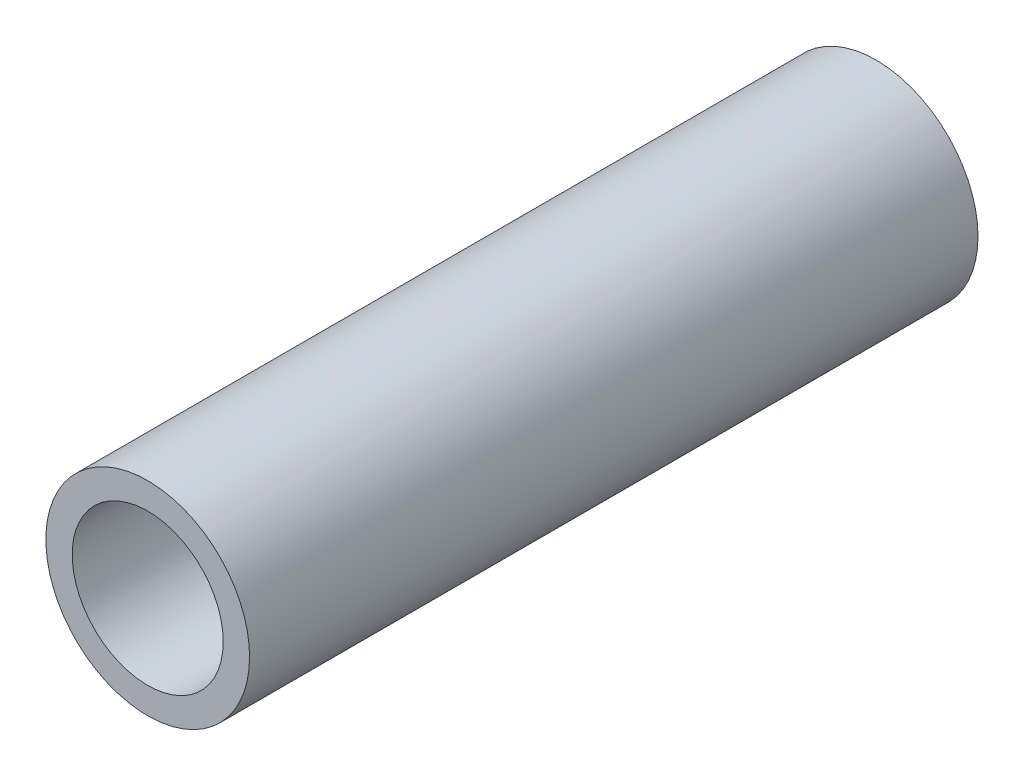
from build123d import *

# Parameters (mm, degrees)
SKETCH1_R           = 10.6553
SKETCH1_R_2         = 7.8994
BOSS_EXTRUDE1_DEPTH = 76.2


with BuildPart() as part:
    # Sketch1 → Boss-Extrude1 (new body)
    with BuildSketch(Plane.XY):
        Circle(SKETCH1_R)
        Circle(SKETCH1_R_2, mode=Mode.SUBTRACT)
    extrude(amount=BOSS_EXTRUDE1_DEPTH)


solid = part.part
